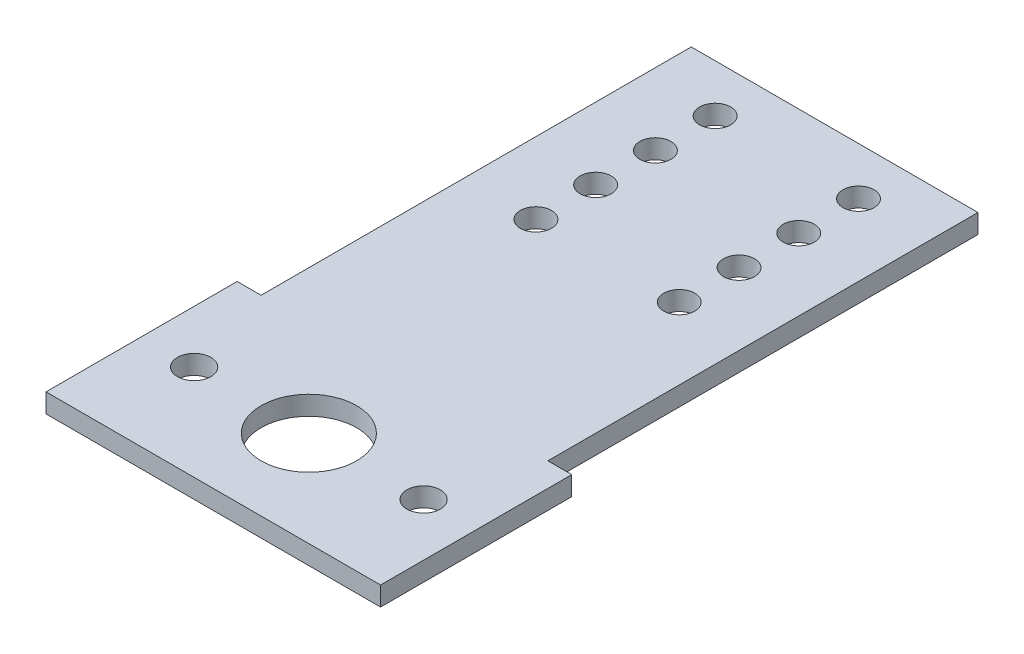
from build123d import *

# Parameters (mm, degrees)
SKETCH1_W           = 60
SKETCH1_H           = 130
BOSS_EXTRUDE1_DEPTH = 4
SKETCH2_W           = 70
SKETCH2_H           = 40
BOSS_EXTRUDE2_DEPTH = 4
SKETCH3_R           = 3.5
SKETCH3_R_2         = 10
CUT_EXTRUDE1_DEPTH  = 5
CUT_EXTRUDE2_START  = -5
SKETCH4_R           = 3.25
CUT_EXTRUDE2_DEPTH  = 6
LPATTERN1_COUNT     = 4
LPATTERN1_PITCH     = 12.5


with BuildPart() as part:
    # Sketch1 → Boss-Extrude1 (new body)
    with BuildSketch(Plane(origin=(0, 0, 0), x_dir=(1, 0, 0), z_dir=(0, 1, 0))):
        Rectangle(SKETCH1_W, SKETCH1_H)
    extrude(amount=BOSS_EXTRUDE1_DEPTH)

    # Sketch2 → Boss-Extrude2 (add)
    with BuildSketch(Plane(origin=(0, 0, 0), x_dir=(1, 0, 0), z_dir=(0, 1, 0))):
        with Locations((0, -45)):
            Rectangle(SKETCH2_W, SKETCH2_H)
    extrude(amount=BOSS_EXTRUDE2_DEPTH)

    # Sketch3 → Cut-Extrude1 (cut, through all)
    with BuildSketch(Plane(origin=(0, 4, 0), x_dir=(1, 0, 0), z_dir=(0, 1, 0))):
        with Locations((24, -45)):
            Circle(SKETCH3_R)
        with Locations((-24, -45)):
            Circle(SKETCH3_R)
        with Locations((0, -45)):
            Circle(SKETCH3_R_2)
    extrude(amount=-CUT_EXTRUDE1_DEPTH, mode=Mode.SUBTRACT)

    # Sketch4 → Cut-Extrude2 (cut)
    with BuildSketch(Plane(origin=(0, 4, 0), x_dir=(1, 0, 0), z_dir=(0, 1, 0)).offset(CUT_EXTRUDE2_START)):
        with Locations((15, 55)):
            Circle(SKETCH4_R)
        with Locations((-15, 55)):
            Circle(SKETCH4_R)
    cut_extrude2 = extrude(amount=CUT_EXTRUDE2_DEPTH, mode=Mode.SUBTRACT)

    # LPattern1: Cut-Extrude2 ×4
    with Locations(*[(0, 0, i * LPATTERN1_PITCH) for i in range(1, LPATTERN1_COUNT)]):
        add(cut_extrude2, mode=Mode.SUBTRACT)


solid = part.part
